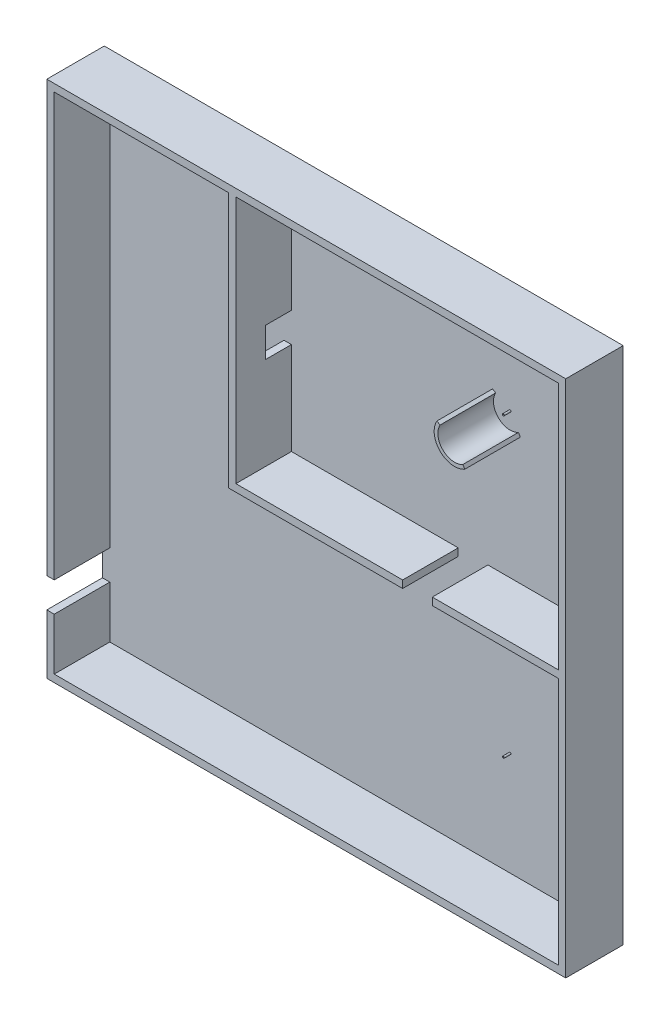
from build123d import *

# Parameters (mm, degrees)
SKETCH_1_W          = 14000
SKETCH_1_H          = 14000
EXTRUDE_1_DEPTH     = 50
SKETCH_2_R          = 25
SKETCH_2_R_2        = 10
EXTRUDE_2_DEPTH     = 1500
SKETCH_3_R          = 25
CUT_EXTRUDE_1_DEPTH = 1300
SKETCH_6_W          = 200
SKETCH_6_H          = 1519.653769674
EXTRUDE_3_DEPTH     = 800


with BuildPart() as part:
    # 草图1 → 凸台-拉伸1 (new body)
    with BuildSketch(Plane.XY):
        Rectangle(SKETCH_1_W, SKETCH_1_H)
    extrude(amount=-EXTRUDE_1_DEPTH)

    # 草图2 → 凸台-拉伸2 (add)
    with BuildSketch(Plane.XY):
        with Locations((4000, -4000)):
            Circle(SKETCH_2_R)
        with Locations((4000, -4000)):
            Circle(SKETCH_2_R_2, mode=Mode.SUBTRACT)
        with Locations((4000, 4000)):
            Circle(SKETCH_2_R)
        with Locations((4000, 4000)):
            Circle(SKETCH_2_R_2, mode=Mode.SUBTRACT)
        Polygon((-7000, 7000), (7000, 7000), (7000, -7000), (-7000, -7000), (-7000, -5400), (-6800, -5400), (-6800, -6800), (6800, -6800), (6800, -100), (3400, -100), (3400, 100), (6800, 100), (6800, 6800), (-1900, 6800), (-1900, 3400), (-2100, 3400), (-2100, 6800), (-6800, 6800), (-6800, -4600), (-7000, -4600), align=None)
        Polygon((2600, 100), (2600, -100), (-2100, -100), (-2100, 2600), (-1900, 2600), (-1900, 100), align=None)
        with BuildLine():
            Line((3523.686027919, 4275), (3610.288568297, 4225))
            ThreePointArc((3610.288568297, 4225), (3681.801948466, 3681.801948466), (4225, 3610.288568297))
            Line((4225, 3610.288568297), (4275, 3523.686027919))
            ThreePointArc((4275, 3523.686027919), (3611.091270347, 3611.091270347), (3523.686027919, 4275))
        make_face()
    extrude(amount=EXTRUDE_2_DEPTH)

    # 草图3 → 切除-拉伸1 (cut)
    with BuildSketch(Plane.XY.offset(1500)):
        with Locations((4000, 4000)):
            Circle(SKETCH_3_R)
        with Locations((4000, -4000)):
            Circle(SKETCH_3_R)
    extrude(amount=-CUT_EXTRUDE_1_DEPTH, mode=Mode.SUBTRACT)

    # 草图5 → 切除-旋转2 (revolve, cut)
    with BuildSketch(Plane(origin=(0, -4000, 0), x_dir=(1, 0, 0), z_dir=(0, 1, 0))):
        with BuildLine():
            Line((4000, -230), (4000, -170))
            ThreePointArc((4000, -170), (3970, -200), (4000, -230))
        make_face()
    cut_revolve_2 = revolve(axis=Axis((4000, -4000, 800), (0, 0, -1)), mode=Mode.SUBTRACT)

    # 镜向1: 切除-旋转2 across plane
    add(cut_revolve_2.mirror(Plane.ZX), mode=Mode.SUBTRACT)

    # 草图6 → 凸台-拉伸3 (add)
    with BuildSketch(Plane.XY.offset(1500)):
        with Locations((-2000, 2912.116810871)):
            Rectangle(SKETCH_6_W, SKETCH_6_H)
    extrude(amount=-EXTRUDE_3_DEPTH)


solid = part.part
